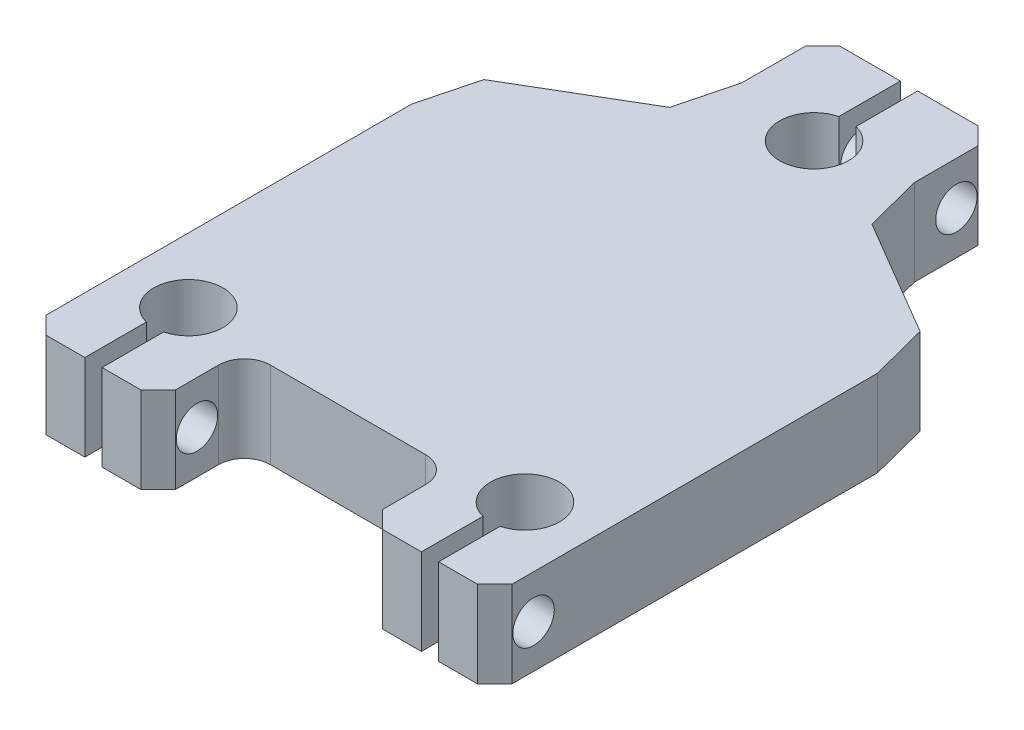
from build123d import *

# Parameters (mm, degrees)
SKETCH1_W             = 24
SKETCH1_H             = 40
BOSS_EXTRUDE1_DEPTH   = 10
SKETCH2_R             = 4
BOSS_EXTRUDE2_DEPTH   = 10
SKETCH4_W             = 2
SKETCH4_H             = 15
CUT_EXTRUDE1_DEPTH    = 20
SKETCH5_R             = 2.4
CUT_EXTRUDE2_DEPTH    = 56
CHAMFER2_SIZE         = 2
CHAMFER3_SIZE2        = 2
CHAMFER3_SIZE         = 5.63516655
CHAMFER3_EDGE_2_SIZE2 = 5.63516655
CHAMFER3_EDGE_2_SIZE  = 2
CHAMFER3_EDGE_3_SIZE2 = 2
CHAMFER3_EDGE_3_SIZE  = 5.63516655
CHAMFER3_EDGE_4_SIZE2 = 5.63516655
CHAMFER3_EDGE_4_SIZE  = 2
FILLET2_R             = 3


with BuildPart() as part:
    # Sketch1 → Boss-Extrude1 (new body)
    with BuildSketch(Plane(origin=(0, 0, 0), x_dir=(1, 0, 0), z_dir=(0, 1, 0))):
        Rectangle(SKETCH1_W, SKETCH1_H)
    extrude(amount=BOSS_EXTRUDE1_DEPTH)

    # Sketch2 → Boss-Extrude2 (add)
    with BuildSketch(Plane.XZ):
        Polygon((-12, -20), (-12, 30), (-27, 30), (-27, -20), (-10, -30), (-10, -45), (10, -45), (10, -30), (27, -20), (27, 30), (12, 30), (12, -20), align=None)
        with Locations((0, -34)):
            Circle(SKETCH2_R, mode=Mode.SUBTRACT)
        with Locations((-19.5, 19)):
            Circle(SKETCH2_R, mode=Mode.SUBTRACT)
        with Locations((19.5, 19)):
            Circle(SKETCH2_R, mode=Mode.SUBTRACT)
    extrude(amount=-BOSS_EXTRUDE2_DEPTH)

    # Sketch4 → Cut-Extrude1 (cut)
    with BuildSketch(Plane(origin=(0, 10, 0), x_dir=(1, 0, 0), z_dir=(0, 1, 0))):
        with Locations((19.5, -30)):
            Rectangle(SKETCH4_W, SKETCH4_H)
        with Locations((-19.5, -30)):
            Rectangle(SKETCH4_W, SKETCH4_H)
        with Locations((0, 45)):
            Rectangle(SKETCH4_W, SKETCH4_H)
    extrude(amount=-CUT_EXTRUDE1_DEPTH, mode=Mode.SUBTRACT)

    # Sketch5 → Cut-Extrude2 (cut)
    with BuildSketch(Plane(origin=(27, 0, 0), x_dir=(0, 0, -1), z_dir=(1, 0, 0))):
        with Locations((-25.5, 5)):
            Circle(SKETCH5_R)
        with Locations((40.5, 5)):
            Circle(SKETCH5_R)
    extrude(amount=-CUT_EXTRUDE2_DEPTH, mode=Mode.SUBTRACT)

    # Chamfer2
    chamfer2_edges = [part.edges().sort_by_distance(p)[0] for p in [
        (-12, 5, 30),
        (12, 5, 30),
        (27, 5, 30),
        (10, 5, -45),
        (-10, 5, -45),
        (-27, 5, 30),
    ]]
    chamfer(chamfer2_edges, length=CHAMFER2_SIZE)

    # Chamfer3
    chamfer3_edges = [part.edges().sort_by_distance(p)[0] for p in [
        (27, 5, -20),
    ]]
    chamfer(chamfer3_edges, length=CHAMFER3_SIZE, length2=CHAMFER3_SIZE2)

    # Chamfer3 edge 2
    chamfer3_edge_2_edges = [part.edges().sort_by_distance(p)[0] for p in [
        (10, 5, -30),
    ]]
    chamfer(chamfer3_edge_2_edges, length=CHAMFER3_EDGE_2_SIZE, length2=CHAMFER3_EDGE_2_SIZE2)

    # Chamfer3 edge 3
    chamfer3_edge_3_edges = [part.edges().sort_by_distance(p)[0] for p in [
        (-10, 5, -30),
    ]]
    chamfer(chamfer3_edge_3_edges, length=CHAMFER3_EDGE_3_SIZE, length2=CHAMFER3_EDGE_3_SIZE2)

    # Chamfer3 edge 4
    chamfer3_edge_4_edges = [part.edges().sort_by_distance(p)[0] for p in [
        (-27, 5, -20),
    ]]
    chamfer(chamfer3_edge_4_edges, length=CHAMFER3_EDGE_4_SIZE, length2=CHAMFER3_EDGE_4_SIZE2)

    # Fillet2
    fillet2_edges = [part.edges().sort_by_distance(p)[0] for p in [
        (12, 5, 20),
        (-12, 5, 20),
    ]]
    fillet(fillet2_edges, radius=FILLET2_R)


solid = part.part
